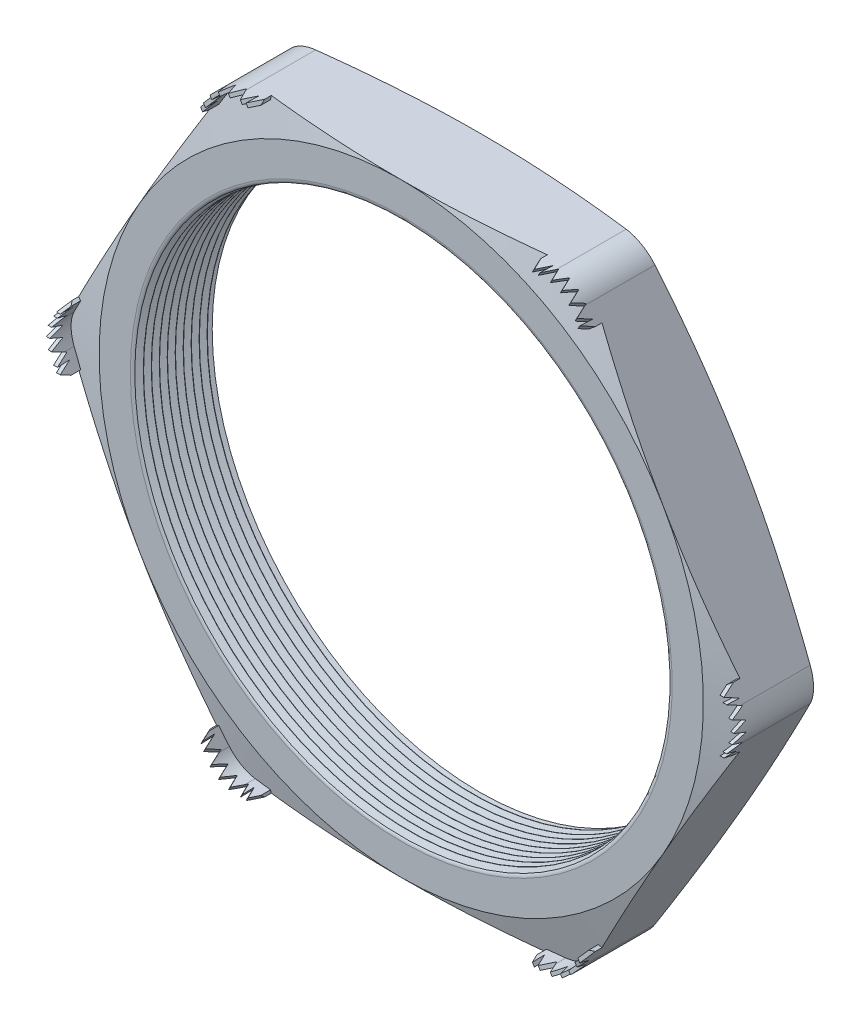
from build123d import *

# Parameters (mm, degrees)
SKETCH1_R          = 10.16
EXTRUDE1_DEPTH     = 3.048
FILLET1_R          = 1.27
FILLET3_R          = 0.2032
LPATTERN1_COUNT    = 10
LPATTERN1_PITCH    = 0.3048
SKETCH4_OUTSIDE_W  = 65.54
SKETCH4_OUTSIDE_H  = 62.358
SKETCH4_OUTSIDE_R  = 11.557
CUT_EXTRUDE1_DEPTH = 4.048
CUT_EXTRUDE1_DRAFT = -75
SKETCH5_OUTSIDE_W  = 65.54
SKETCH5_OUTSIDE_H  = 62.358
SKETCH5_OUTSIDE_R  = 11.557
CUT_EXTRUDE2_DEPTH = 4.0480001
CUT_EXTRUDE2_DRAFT = -75
EXTRUDE2_START     = -0.426416
EXTRUDE2_DEPTH     = 1.569416
CUT_EXTRUDE4_DEPTH = 5.044786472
CIRPATTERN1_COUNT  = 6
CIRPATTERN2_COUNT  = 6


with BuildPart() as part:
    # Sketch1 → Extrude1 (new body)
    with BuildSketch(Plane.XY):
        Polygon((-13.344874122, 0), (-6.672437061, -11.557), (6.672437061, -11.557), (13.344874122, 0), (6.672437061, 11.557), (-6.672437061, 11.557), align=None)
        Circle(SKETCH1_R, mode=Mode.SUBTRACT)
    extrude(amount=EXTRUDE1_DEPTH)

    # Fillet1
    fillet1_edges = [part.edges().sort_by_distance(p)[0] for p in [
        (13.344874122, 0, 1.524),
        (6.672437061, -11.557, 1.524),
        (-6.672437061, -11.557, 1.524),
        (-13.344874122, 0, 1.524),
        (-6.672437061, 11.557, 1.524),
        (6.672437061, 11.557, 1.524),
    ]]
    fillet(fillet1_edges, radius=FILLET1_R)

    # Fillet3
    fillet3_edges = [part.edges().sort_by_distance(p)[0] for p in [
        (-10.16, 0, 0),
        (-10.16, 0, 3.048),
    ]]
    fillet(fillet3_edges, radius=FILLET3_R)

    # Sketch3 → Cut-Revolve1 (revolve, cut)
    with BuildSketch(Plane(origin=(0, 0, 0), x_dir=(1, 0, 0), z_dir=(0, 1, 0))):
        Polygon((-10.16, -3.048), (-10.16, -2.754706063), (-10.414, -2.901353032), align=None)
    cut_revolve1 = revolve(axis=Axis((0, 0, 3.048), (0, 0, -1)), mode=Mode.SUBTRACT)

    # LPattern1: Cut-Revolve1 ×10
    with Locations(*[(0, 0, -i * LPATTERN1_PITCH) for i in range(1, LPATTERN1_COUNT)]):
        add(cut_revolve1, mode=Mode.SUBTRACT)


with BuildPart() as cut_extrude1_tool:
    # Sketch4 outside → Cut-Extrude1 (with draft: the straight prism first)
    with BuildSketch(Plane(origin=(0, 0, 0), x_dir=(-1, 0, 0), z_dir=(0, 0, -1))):
        Rectangle(SKETCH4_OUTSIDE_W, SKETCH4_OUTSIDE_H)
        Circle(SKETCH4_OUTSIDE_R, mode=Mode.SUBTRACT)
    extrude(amount=-CUT_EXTRUDE1_DEPTH)
    # Cut-Extrude1: the draft: its side faces are tilted about the plane it starts from
    cut_extrude1_sides = [cut_extrude1_tool.faces().sort_by_distance(p)[0] for p in [
        (0, -31.179, 2.024),
        (-32.77, 0, 2.024),
        (0, 31.179, 2.024),
        (32.77, 0, 2.024),
        (11.557, 0, 2.024),
    ]]
    draft(cut_extrude1_sides, Plane(origin=(0, 0, 0), x_dir=(-1, 0, 0), z_dir=(0, 0, -1)), CUT_EXTRUDE1_DRAFT)


with BuildPart() as part_1:
    add(part.part)

    # Cut-Extrude1: cut by cut_extrude1_tool
    add(cut_extrude1_tool.part, mode=Mode.SUBTRACT)


with BuildPart() as cut_extrude2_tool:
    # Sketch5 outside → Cut-Extrude2 (with draft: the straight prism first)
    with BuildSketch(Plane.XY.offset(3.048)):
        Rectangle(SKETCH5_OUTSIDE_W, SKETCH5_OUTSIDE_H)
        Circle(SKETCH5_OUTSIDE_R, mode=Mode.SUBTRACT)
    extrude(amount=-CUT_EXTRUDE2_DEPTH)
    # Cut-Extrude2: the draft: its side faces are tilted about the plane it starts from
    cut_extrude2_sides = [cut_extrude2_tool.faces().sort_by_distance(p)[0] for p in [
        (0, -31.179, 1.02399995),
        (32.77, 0, 1.02399995),
        (0, 31.179, 1.02399995),
        (-32.77, 0, 1.02399995),
        (-11.557, 0, 1.02399995),
    ]]
    draft(cut_extrude2_sides, Plane.XY.offset(3.048), CUT_EXTRUDE2_DRAFT)


with BuildPart() as part_2:
    add(part_1.part)

    # Cut-Extrude2: cut by cut_extrude2_tool
    add(cut_extrude2_tool.part, mode=Mode.SUBTRACT)

    # Sketch2 → Extrude2 (add)
    with BuildSketch(Plane.XY.offset(3.048).offset(EXTRUDE2_START)):
        with BuildLine():
            Line((-5.939202219, 11.557), (-5.278802219, 11.557))
            Line((-5.278802219, 11.557), (-5.278802219, 11.43))
            Line((-5.278802219, 11.43), (-5.939202219, 11.43))
            ThreePointArc((-5.939202219, 11.43), (-6.510702219, 11.276867037), (-6.929069256, 10.8585))
            Line((-6.929069256, 10.8585), (-7.259269256, 10.286576823))
            Line((-7.259269256, 10.286576823), (-7.369254482, 10.350076823))
            Line((-7.369254482, 10.350076823), (-7.039054482, 10.922))
            ThreePointArc((-7.039054482, 10.922), (-6.574202219, 11.386852263), (-5.939202219, 11.557))
        make_face()
    extrude2 = extrude(amount=EXTRUDE2_DEPTH)

    # Sketch7 → Cut-Extrude4 (cut, through all)
    with BuildSketch(Plane(origin=(-6.269035737, 10.858288412, 0), x_dir=(0.866025404, 0.5, 0), z_dir=(0.5, -0.866025404, 0))):
        Polygon((-1.206923177, 2.99085), (-1.003723177, 3.47091), (-0.800523177, 2.99085), (-0.8128, 3.47091), (-0.6096, 2.99085), (-0.4064, 3.47091), (-0.2032, 2.99085), (0, 3.47091), (0.2032, 2.99085), (0.4064, 3.47091), (0.6096, 2.99085), (0.8128, 3.47091), (1.016, 2.99085), (1.003723177, 3.47091), (1.206923177, 2.99085), (1.206923177, 4.191), (-1.206923177, 4.191), align=None)
    cut_extrude4 = extrude(amount=-CUT_EXTRUDE4_DEPTH, mode=Mode.SUBTRACT)

    # CirPattern1: Extrude2 ×6 about axis
    cirpattern1_axis = Axis((0, 0, 0), (0, 0, 1))
    for i in range(1, CIRPATTERN1_COUNT):
        add(extrude2.rotate(cirpattern1_axis, i * 360 / CIRPATTERN1_COUNT))

    # CirPattern2: Cut-Extrude4 ×6 about axis
    cirpattern2_axis = Axis((0, 0, 0), (0, 0, 1))
    for i in range(1, CIRPATTERN2_COUNT):
        add(cut_extrude4.rotate(cirpattern2_axis, i * 360 / CIRPATTERN2_COUNT), mode=Mode.SUBTRACT)


solid = part_2.part
